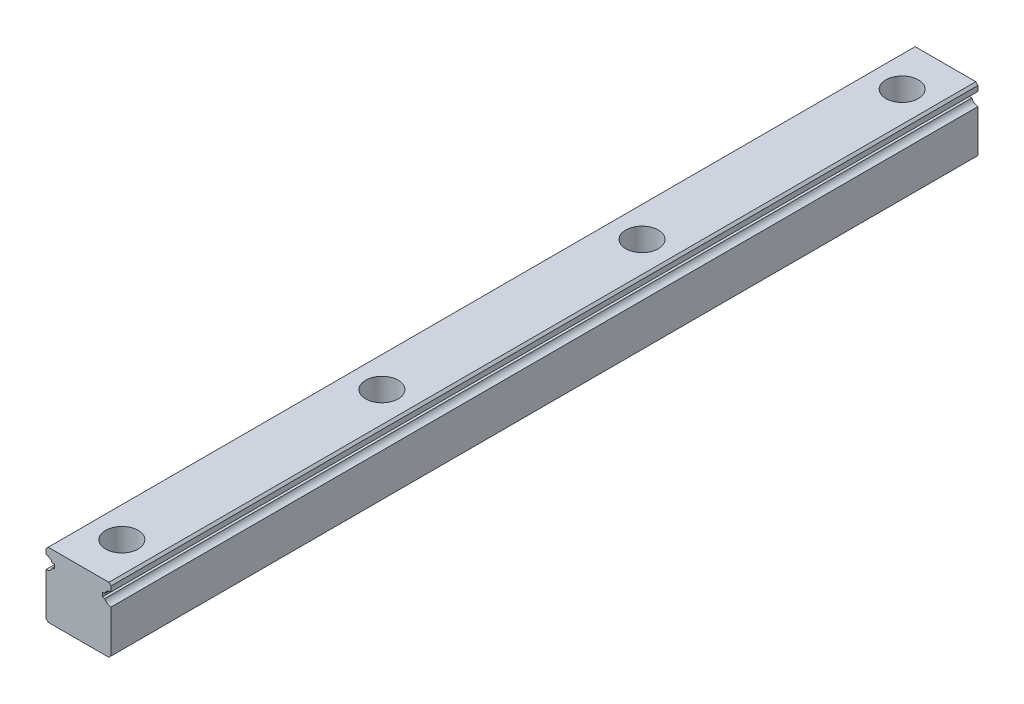
from build123d import *

# Parameters (mm, degrees)
BOSS_EXTRUDE1_DEPTH                                 = 200
CUT_EXTRUDE1_START                                  = -200
SKETCH2_R                                           = 1.5
CUT_EXTRUDE1_DEPTH                                  = 200
CHAMFER1_SIZE                                       = 0.5
CHAMFER2_SIZE                                       = 0.5
CBORE_FOR_M4_HEX_SOCKET_HEAD_CAP_SCREW1_D           = 4.5
CBORE_FOR_M4_HEX_SOCKET_HEAD_CAP_SCREW1_CBORE_D     = 7.5
CBORE_FOR_M4_HEX_SOCKET_HEAD_CAP_SCREW1_CBORE_DEPTH = 5.3
LPATTERN1_COUNT                                     = 4
LPATTERN1_PITCH                                     = 60


with BuildPart() as part:
    # Sketch1 → Boss-Extrude1 (new body)
    with BuildSketch(Plane.XY):
        Polygon((7.5, 0), (-7.5, 0), (-7.5, 11.3), (-5.5, 11.3), (-5.5, 12.3), (-7.5, 12.3), (-7.5, 15), (7.5, 15), (7.5, 12.3), (5.5, 12.3), (5.5, 11.3), (7.5, 11.3), align=None)
    extrude(amount=BOSS_EXTRUDE1_DEPTH)

    # Sketch2 → Cut-Extrude1 (cut)
    with BuildSketch(Plane.XY.offset(200).offset(CUT_EXTRUDE1_START)):
        with Locations((-7.5, 11.8)):
            Circle(SKETCH2_R)
        with Locations((7.5, 11.8)):
            Circle(SKETCH2_R)
    extrude(amount=CUT_EXTRUDE1_DEPTH, mode=Mode.SUBTRACT)

    # Chamfer1
    chamfer1_edges = [part.edges().sort_by_distance(p)[0] for p in [
        (-7.5, 15, 100),
        (7.5, 15, 100),
    ]]
    chamfer(chamfer1_edges, length=CHAMFER1_SIZE)

    # Chamfer2
    chamfer2_edges = [part.edges().sort_by_distance(p)[0] for p in [
        (7.5, 0, 100),
        (-7.5, 0, 100),
    ]]
    chamfer(chamfer2_edges, length=CHAMFER2_SIZE)

    # CBORE for M4 Hex Socket Head Cap Screw1 (through all)
    with Locations(Plane(origin=(0, 15, 190), x_dir=(0, 0, 1), z_dir=(0, 1, 0))):
        with Locations((0, 0)):
            cbore_for_m4_hex_socket_head_cap_screw1 = CounterBoreHole(CBORE_FOR_M4_HEX_SOCKET_HEAD_CAP_SCREW1_D / 2, CBORE_FOR_M4_HEX_SOCKET_HEAD_CAP_SCREW1_CBORE_D / 2, CBORE_FOR_M4_HEX_SOCKET_HEAD_CAP_SCREW1_CBORE_DEPTH)

    # LPattern1: CBORE for M4 Hex Socket Head Cap Screw1 ×4
    with Locations(*[(0, 0, -i * LPATTERN1_PITCH) for i in range(1, LPATTERN1_COUNT)]):
        add(cbore_for_m4_hex_socket_head_cap_screw1, mode=Mode.SUBTRACT)


solid = part.part
